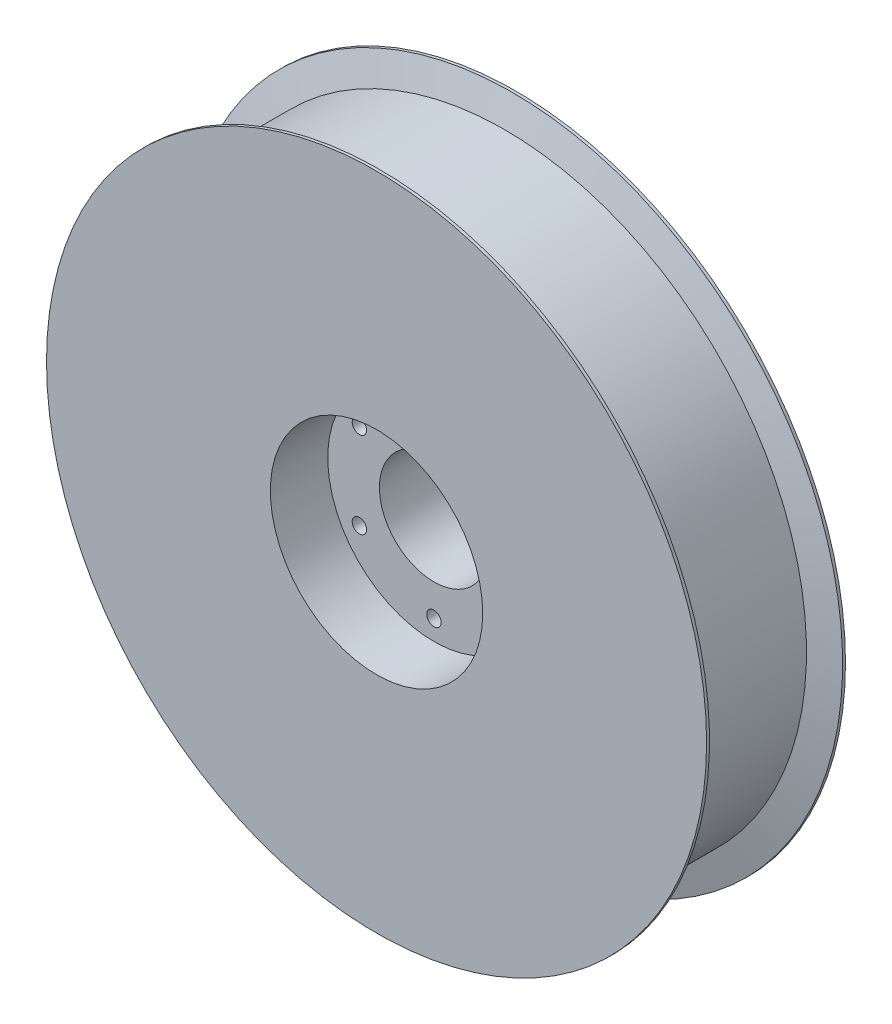
from build123d import *

# Parameters (mm, degrees)
SKETCH_1_R          = 57.5
SKETCH_1_R_2        = 9.5
EXTRUDE_1_DEPTH     = 24.2
SKETCH_3_R          = 18.5
SKETCH_3_R_2        = 9.5
CUT_EXTRUDE_2_DEPTH = 10
SKETCH_4_R          = 1.25
CUT_EXTRUDE_3_DEPTH = 25.2


with BuildPart() as part:
    # 草圖1 → 填料-伸長1 (new body)
    with BuildSketch(Plane.XY):
        Circle(SKETCH_1_R)
        Circle(SKETCH_1_R_2, mode=Mode.SUBTRACT)
    extrude(amount=EXTRUDE_1_DEPTH)

    # 草圖3 → 除料-伸長2 (cut)
    with BuildSketch(Plane.XY.offset(24.2)):
        Circle(SKETCH_3_R)
        Circle(SKETCH_3_R_2, mode=Mode.SUBTRACT)
    extrude(amount=-CUT_EXTRUDE_2_DEPTH, mode=Mode.SUBTRACT)

    # 草圖4 → 除料-伸長3 (cut, through all)
    with BuildSketch(Plane(origin=(0, 0, 0), x_dir=(-1, 0, 0), z_dir=(0, 0, -1))):
        with Locations((0, 15)):
            Circle(SKETCH_4_R)
        with Locations((12.990381057, -7.5)):
            Circle(SKETCH_4_R)
        with Locations((-12.990381057, -7.5)):
            Circle(SKETCH_4_R)
        with Locations((12.990381057, 7.5)):
            Circle(SKETCH_4_R)
        with Locations((0, -15)):
            Circle(SKETCH_4_R)
        with Locations((-12.990381057, 7.5)):
            Circle(SKETCH_4_R)
    extrude(amount=-CUT_EXTRUDE_3_DEPTH, mode=Mode.SUBTRACT)

    # 草圖5 → 除料-旋轉1 (revolve, cut)
    with BuildSketch(Plane(origin=(0, 0, 0), x_dir=(1, 0, 0), z_dir=(0, 1, 0))):
        Polygon((57.5, -23.7), (52.555, -22.35), (52.555, -1.85), (57.5, -0.5), align=None)
    revolve(axis=Axis((0, 0, 0), (0, 0, 1)), mode=Mode.SUBTRACT)


solid = part.part
